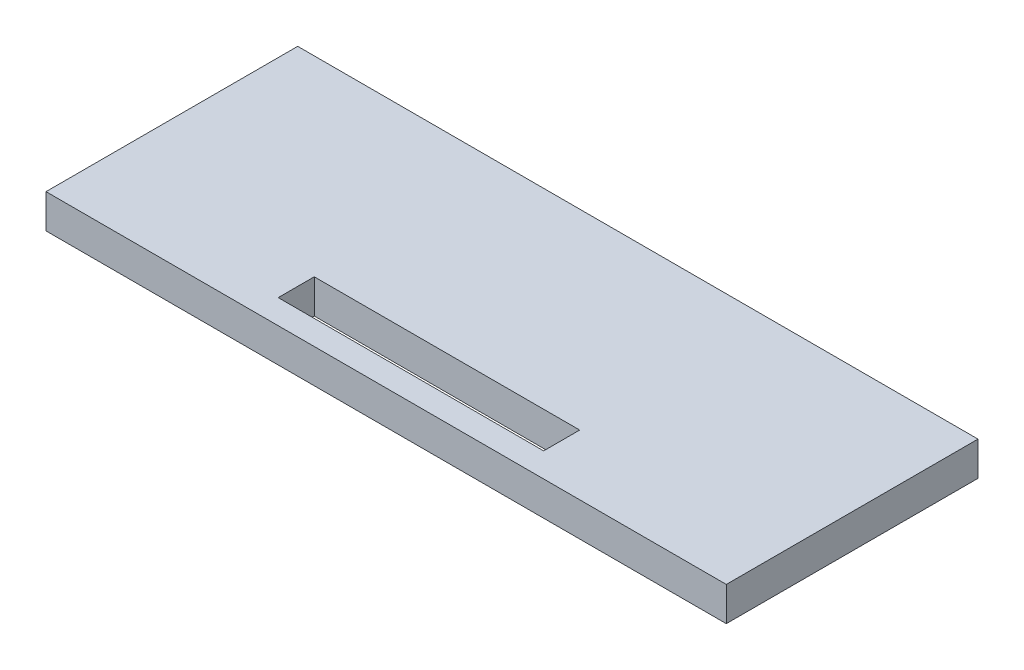
from build123d import *

# Parameters (mm, degrees)
CROQUIS1_W                 = 100
CROQUIS1_H                 = 4.000000012
SALIENTE_EXTRUIR1_DEPTH    = 37
CROQUIS2_W                 = 100
CROQUIS2_H                 = 37
SALIENTE_EXTRUIR2_DEPTH    = 1
CORTAR_EXTRUIR1_DEPTH      = 1
CORTAR_EXTRUIR1_DEPTH_BACK = 10


with BuildPart() as part:
    # Croquis1 → Saliente-Extruir1 (new body)
    with BuildSketch(Plane.XY):
        with Locations((2.8e-08, 88.602540372)):
            Rectangle(CROQUIS1_W, CROQUIS1_H)
    extrude(amount=SALIENTE_EXTRUIR1_DEPTH)

    # Croquis2 → Saliente-Extruir2 (add)
    with BuildSketch(Plane(origin=(0, 90.602540378, 0), x_dir=(1, 0, 0), z_dir=(0, 1, 0))):
        with Locations((2.8e-08, -18.5)):
            Rectangle(CROQUIS2_W, CROQUIS2_H)
    extrude(amount=SALIENTE_EXTRUIR2_DEPTH)

    # Croquis3 → Cortar-Extruir1 (cut, two sides)
    with BuildSketch(Plane(origin=(0, 91.602540378, 0), x_dir=(1, 0, 0), z_dir=(0, 1, 0))) as cortar_extruir1_sk:
        Polygon((-19.443089963, -28.124409531), (-19.443089963, -33.424409531), (0.06597073, -33.424409531), (19.575031424, -33.424409531), (19.575031424, -28.124409531), (0.103924104, -28.124409531), (0.028017356, -28.124409531), align=None)
    extrude(amount=CORTAR_EXTRUIR1_DEPTH, mode=Mode.SUBTRACT)
    extrude(cortar_extruir1_sk.sketch, amount=-CORTAR_EXTRUIR1_DEPTH_BACK, mode=Mode.SUBTRACT)


solid = part.part
